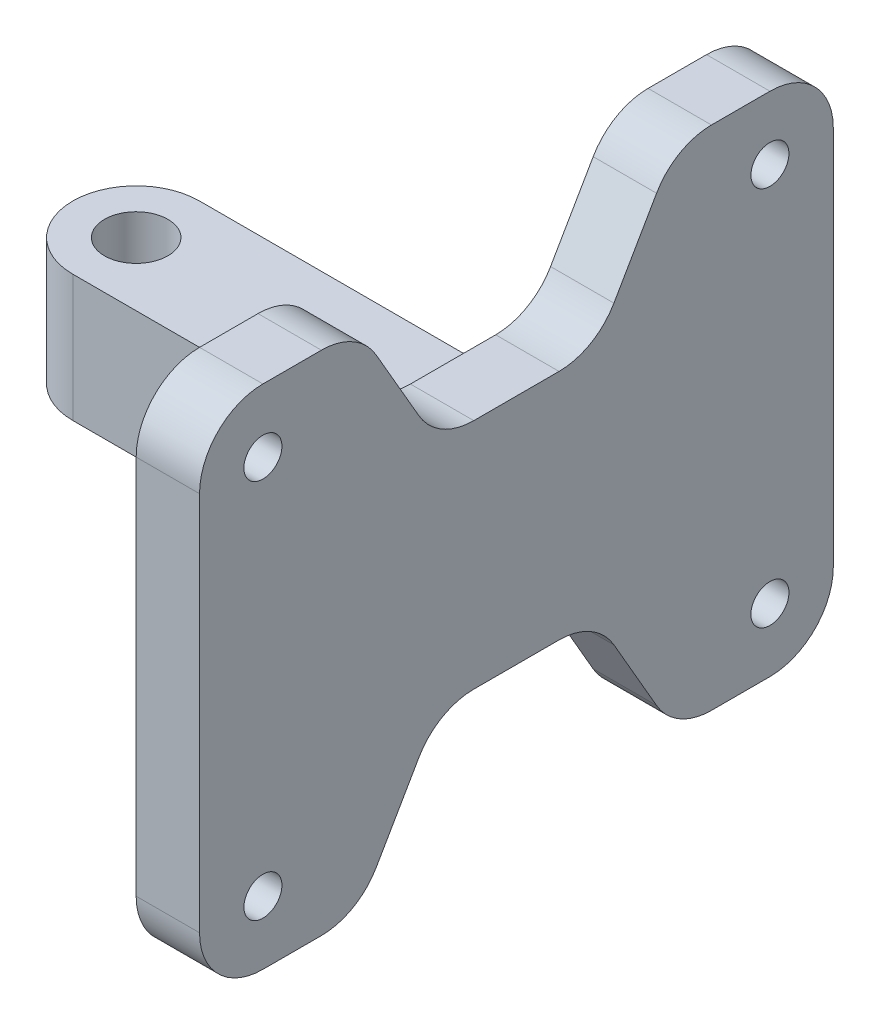
from build123d import *

# Parameters (mm, degrees)
SKETCH1_W            = 100
SKETCH1_H            = 80
PLATE_DEPTH          = 10
HEXAGONAL_CUTS_DEPTH = 65.807406984
SKETCH3_R            = 3
F_6MM_HOLES_DEPTH    = 65.807406984
FILLET1_R            = 10
SKETCH4_W            = 20
SKETCH4_H            = 20
SWIVEL_DEPTH         = 60
FILLET2_RADIUS       = 10
FILLET2_LENGTH       = 20
SKETCH5_R            = 5
F_10MM_HOLE_DEPTH    = 93.736184955


with BuildPart() as part:
    # Sketch1 → plate (new body)
    with BuildSketch(Plane(origin=(0, 0, 0), x_dir=(0, 0, -1), z_dir=(1, 0, 0))):
        Rectangle(SKETCH1_W, SKETCH1_H)
    extrude(amount=PLATE_DEPTH)

    # Sketch2 → hexagonal cuts (cut, through all)
    with BuildSketch(Plane(origin=(10, 0, 0), x_dir=(0, 0, -1), z_dir=(1, 0, 0))):
        Polygon((-25, 40), (-12.5, 18.349364905), (12.5, 18.349364905), (25, 40), (12.5, 61.650635095), (-12.5, 61.650635095), align=None)
        Polygon((25, -40), (12.5, -61.650635095), (-12.5, -61.650635095), (-25, -40), (-12.5, -18.349364905), (12.5, -18.349364905), align=None)
    extrude(amount=-HEXAGONAL_CUTS_DEPTH, mode=Mode.SUBTRACT)

    # Sketch3 → 6mm holes (cut, through all)
    with BuildSketch(Plane(origin=(10, 0, 0), x_dir=(0, 0, -1), z_dir=(1, 0, 0))):
        with Locations((-40, 30)):
            Circle(SKETCH3_R)
        with Locations(Location((40, 30, 0), (0, 0, 180))):
            Circle(SKETCH3_R)
        with Locations((40, -30)):
            Circle(SKETCH3_R)
        with Locations(Location((-40, -30, 0), (0, 0, 180))):
            Circle(SKETCH3_R)
    extrude(amount=-F_6MM_HOLES_DEPTH, mode=Mode.SUBTRACT)

    # Fillet1
    fillet1_edges = [part.edges().sort_by_distance(p)[0] for p in [
        (5, 40, 25),
        (5, 40, -25),
        (5, 18.349364905, -12.5),
        (5, 18.349364905, 12.5),
        (5, -18.349364905, -12.5),
        (5, -40, -25),
        (5, -40, 25),
        (5, -18.349364905, 12.5),
        (5, 40, 50),
        (5, 40, -50),
        (5, -40, -50),
        (5, -40, 50),
    ]]
    fillet(fillet1_edges, radius=FILLET1_R)

    # Sketch4 → Swivel (add)
    with BuildSketch(Plane.ZY):
        Rectangle(SKETCH4_W, SKETCH4_H)
    extrude(amount=SWIVEL_DEPTH)

    # Fillet2: full round fillet: the end face becomes a half cylinder, R = half its width
    fillet2_face = Plane((-60, 0, 0), x_dir=(0, 1, 0), z_dir=(-1, 0, 0))  # on the end face: x along it, z out of the body
    fillet2_slab = fillet2_face.offset(-FILLET2_RADIUS / 2) * Box(FILLET2_LENGTH, 2 * FILLET2_RADIUS, FILLET2_RADIUS, mode=Mode.PRIVATE)  # the body's end, R deep
    fillet2_round = Plane((-50, 0, 0), x_dir=(-1, 0, 0), z_dir=(0, 1, 0)) * Cylinder(FILLET2_RADIUS, FILLET2_LENGTH, mode=Mode.PRIVATE)  # its axis R under the face
    add(fillet2_slab - fillet2_round, mode=Mode.SUBTRACT)

    # Sketch5 → 10mm hole (cut, through all)
    with BuildSketch(Plane(origin=(0, 10, 0), x_dir=(1, 0, 0), z_dir=(0, 1, 0))):
        with Locations(Location((-50, 0, 0), (0, 0, 270))):
            Circle(SKETCH5_R)
    extrude(amount=-F_10MM_HOLE_DEPTH, mode=Mode.SUBTRACT)


solid = part.part
